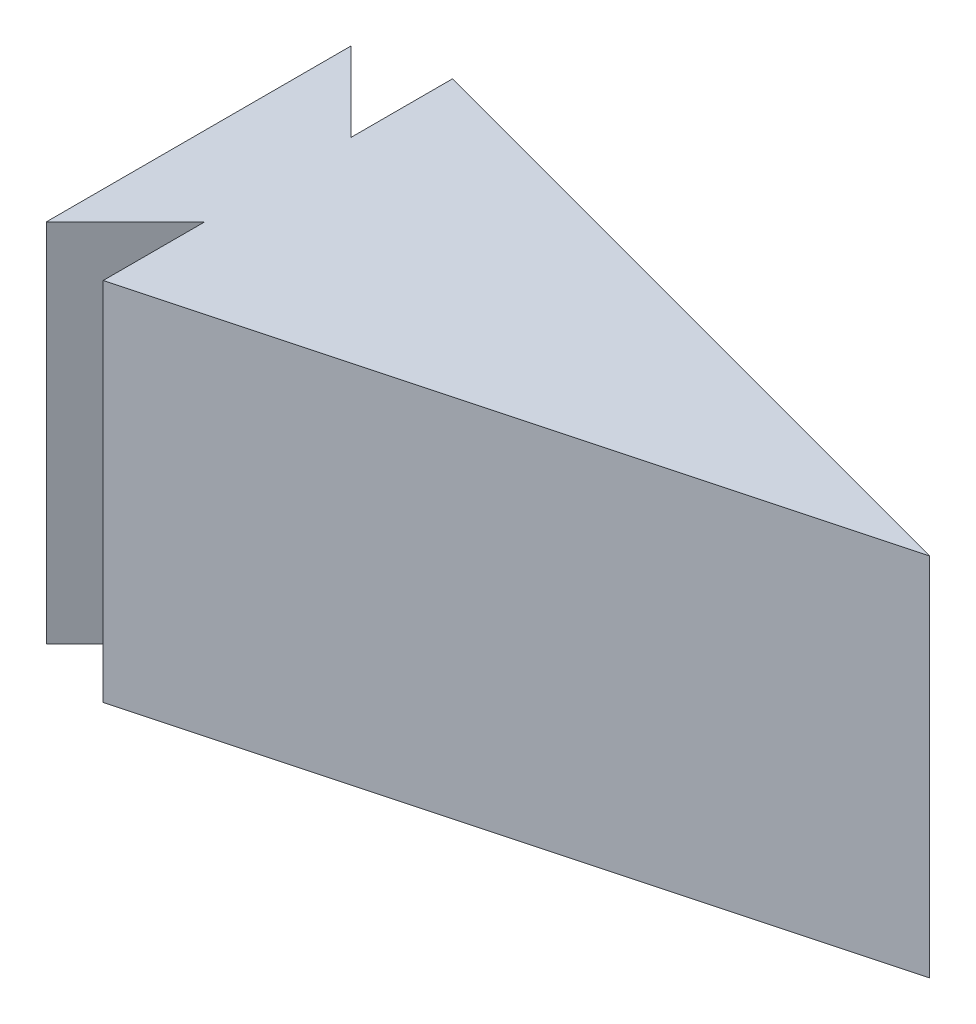
from build123d import *

# Parameters (mm, degrees)
BOSS_EXTRUDE1_DEPTH = 38.1


with BuildPart() as part:
    # Sketch1 → Boss-Extrude1 (new body)
    with BuildSketch(Plane(origin=(0, 0, 0), x_dir=(1, 0, 0), z_dir=(0, 1, 0))):
        Polygon((0, 0), (0, 31.75), (8.255, 23.495), (8.255, 34.08080788), (76.2, 15.875), (8.255, -2.33080788), (8.255, 8.255), align=None)
    extrude(amount=BOSS_EXTRUDE1_DEPTH)


solid = part.part
